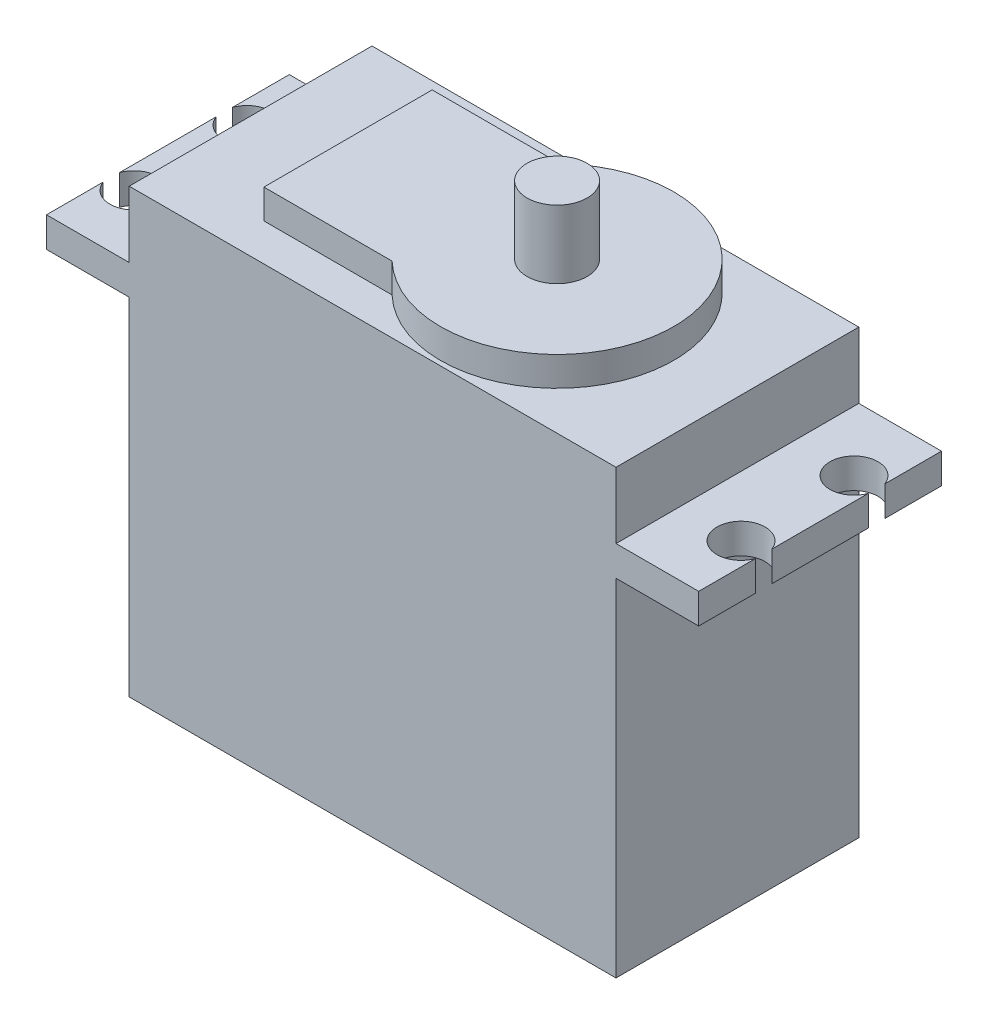
from build123d import *

# Parameters (mm, degrees)
CROQUIS1_W              = 40.5
CROQUIS1_H              = 20.2
SALIENTE_EXTRUIR1_DEPTH = 36.8
CROQUIS2_R              = 9.710333118
SALIENTE_EXTRUIR2_DEPTH = 2.44
CROQUIS3_R              = 2.5
SALIENTE_EXTRUIR3_DEPTH = 5.66
CROQUIS4_W              = 20.2
CROQUIS4_H              = 2.5
SALIENTE_EXTRUIR4_DEPTH = 6.88
CROQUIS5_W              = 20.2
CROQUIS5_H              = 2.5
SALIENTE_EXTRUIR5_DEPTH = 6.88
CORTAR_EXTRUIR1_DEPTH   = 32.3


with BuildPart() as part:
    # Croquis1 → Saliente-Extruir1 (new body)
    with BuildSketch(Plane(origin=(0, 0, 0), x_dir=(1, 0, 0), z_dir=(0, 1, 0))):
        with Locations((20.25, 10.1)):
            Rectangle(CROQUIS1_W, CROQUIS1_H)
    extrude(amount=SALIENTE_EXTRUIR1_DEPTH)

    # Croquis2 → Saliente-Extruir2 (add)
    with BuildSketch(Plane(origin=(0, 36.8, 0), x_dir=(1, 0, 0), z_dir=(0, 1, 0))):
        with Locations((25.5, 10.1)):
            Circle(CROQUIS2_R)
        with BuildLine():
            Line((18.770173162, 17.1), (8.106469176, 17.1))
            Line((8.106469176, 17.1), (8.106469176, 3.1))
            Line((8.106469176, 3.1), (18.770173162, 3.1))
            ThreePointArc((18.770173162, 3.1), (15.789666882, 10.1), (18.770173162, 17.1))
        make_face()
    extrude(amount=SALIENTE_EXTRUIR2_DEPTH)

    # Croquis3 → Saliente-Extruir3 (add)
    with BuildSketch(Plane(origin=(0, 39.24, 0), x_dir=(1, 0, 0), z_dir=(0, 1, 0))):
        with Locations((25.5, 10.1)):
            Circle(CROQUIS3_R)
    extrude(amount=SALIENTE_EXTRUIR3_DEPTH)

    # Croquis4 → Saliente-Extruir4 (add)
    with BuildSketch(Plane.ZY):
        with Locations((-10.1, 30.05)):
            Rectangle(CROQUIS4_W, CROQUIS4_H)
    extrude(amount=SALIENTE_EXTRUIR4_DEPTH)

    # Croquis5 → Saliente-Extruir5 (add)
    with BuildSketch(Plane(origin=(40.5, 0, 0), x_dir=(0, 0, -1), z_dir=(1, 0, 0))):
        with Locations((10.1, 30.05)):
            Rectangle(CROQUIS5_W, CROQUIS5_H)
    extrude(amount=SALIENTE_EXTRUIR5_DEPTH)

    # Croquis6 → Cortar-Extruir1 (cut, through all)
    with BuildSketch(Plane(origin=(0, 31.3, 0), x_dir=(1, 0, 0), z_dir=(0, 1, 0))):
        with BuildLine():
            ThreePointArc((-6.88, 4.717651116), (-3, 5.4), (-6.88, 6.082348884))
            Line((-6.88, 6.082348884), (-6.88, 4.717651116))
        make_face()
        with BuildLine():
            ThreePointArc((-6.88, 14.117651116), (-3, 14.8), (-6.88, 15.482348884))
            Line((-6.88, 15.482348884), (-6.88, 14.117651116))
        make_face()
        with BuildLine():
            Line((47.38, 14.117651116), (47.38, 15.482348884))
            ThreePointArc((47.38, 15.482348884), (43.5, 14.8), (47.38, 14.117651116))
        make_face()
        with BuildLine():
            Line((47.38, 4.717651116), (47.38, 6.082348884))
            ThreePointArc((47.38, 6.082348884), (43.5, 5.4), (47.38, 4.717651116))
        make_face()
    extrude(amount=-CORTAR_EXTRUIR1_DEPTH, mode=Mode.SUBTRACT)


solid = part.part
